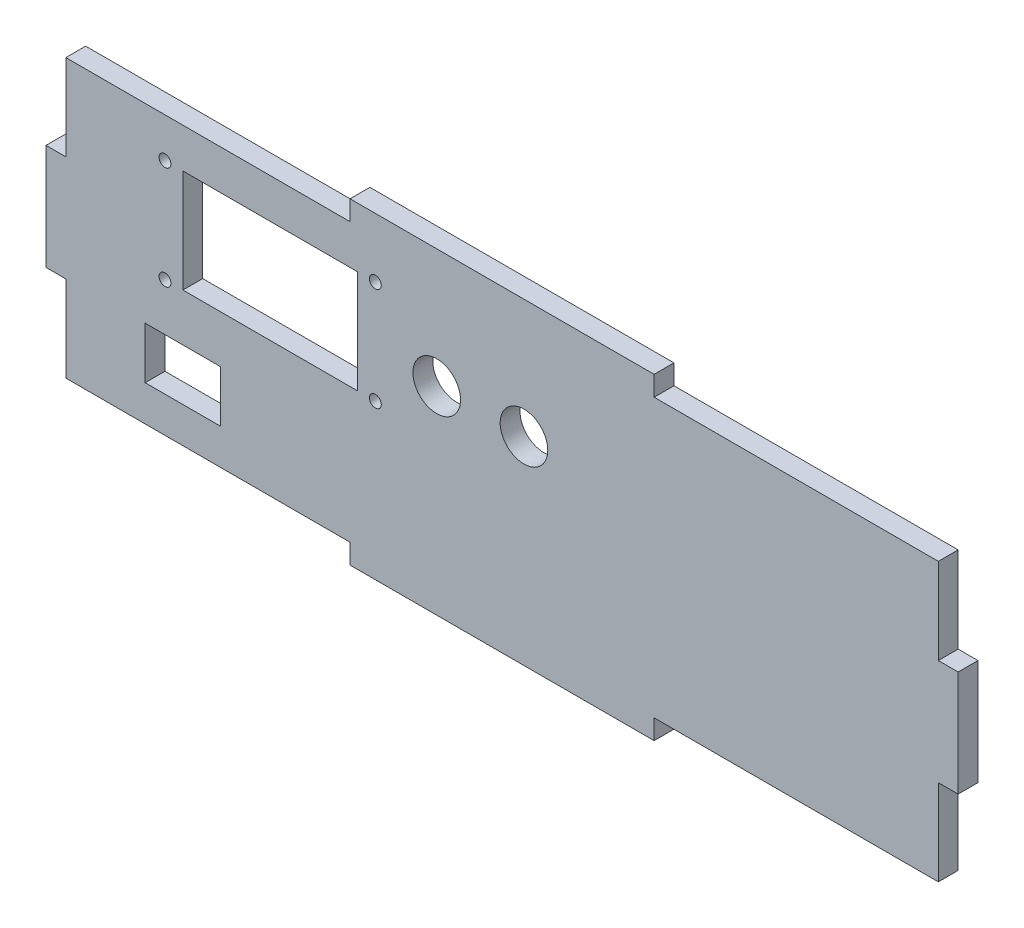
from build123d import *

# Parameters (mm, degrees)
CROQUIS1_R              = 1.5
CROQUIS1_W              = 44
CROQUIS1_H              = 26
CROQUIS1_W_2            = 5
CROQUIS1_H_2            = 26.666666666
CROQUIS1_W_3            = 76.666666666
CROQUIS1_H_3            = 5
SALIENTE_EXTRUIR1_DEPTH = 5
CROQUIS2_R              = 4.15
CORTAR_EXTRUIR1_DEPTH   = 10
CROQUIS3_W              = 19
CROQUIS3_H              = 13
CORTAR_EXTRUIR2_DEPTH   = 10
CROQUIS4_R              = 4.15
CORTAR_EXTRUIR3_DEPTH   = 10
CROQUIS5_R              = 6
CORTAR_EXTRUIR4_DEPTH   = 10
CROQUIS7_W              = 87.958060954
CROQUIS7_H              = 14.714173765
SALIENTE_EXTRUIR2_DEPTH = 5


with BuildPart() as part:
    # Croquis1 → Saliente-Extruir1 (new body)
    with BuildSketch(Plane.XY):
        Polygon((5, 26.666666667), (5, 5), (76.666666667, 5), (153.333333333, 5), (225, 5), (225, 26.666666667), (225, 53.333333333), (225, 75), (153.333333333, 75), (76.666666667, 75), (5, 75), (5, 53.333333333), align=None)
        with Locations((30, 39)):
            Circle(CROQUIS1_R, mode=Mode.SUBTRACT)
        with Locations((83.04, 39)):
            Circle(CROQUIS1_R, mode=Mode.SUBTRACT)
        with Locations((56.52, 52)):
            Rectangle(CROQUIS1_W, CROQUIS1_H, mode=Mode.SUBTRACT)
        with Locations((30, 65)):
            Circle(CROQUIS1_R, mode=Mode.SUBTRACT)
        with Locations((83.04, 65)):
            Circle(CROQUIS1_R, mode=Mode.SUBTRACT)
        with Locations((227.5, 40)):
            Rectangle(CROQUIS1_W_2, CROQUIS1_H_2)
        with Locations((115, 2.5)):
            Rectangle(CROQUIS1_W_3, CROQUIS1_H_3)
        with Locations((2.5, 40)):
            Rectangle(CROQUIS1_W_2, CROQUIS1_H_2)
        with Locations((115, 77.5)):
            Rectangle(CROQUIS1_W_3, CROQUIS1_H_3)
    extrude(amount=SALIENTE_EXTRUIR1_DEPTH)

    # Croquis2 → Cortar-Extruir1 (cut)
    with BuildSketch(Plane.XY.offset(5)):
        with Locations((96.666666667, 20)):
            Circle(CROQUIS2_R)
        with Locations((116.666666667, 20)):
            Circle(CROQUIS2_R)
        with Locations((136.666666667, 20)):
            Circle(CROQUIS2_R)
    extrude(amount=-CORTAR_EXTRUIR1_DEPTH, mode=Mode.SUBTRACT)

    # Croquis3 → Cortar-Extruir2 (cut)
    with BuildSketch(Plane.XY.offset(5)):
        with Locations((34.5, 20.5)):
            Rectangle(CROQUIS3_W, CROQUIS3_H)
    extrude(amount=-CORTAR_EXTRUIR2_DEPTH, mode=Mode.SUBTRACT)

    # Croquis4 → Cortar-Extruir3 (cut)
    with BuildSketch(Plane.XY.offset(5)):
        with Locations((65, 20)):
            Circle(CROQUIS4_R)
        with Locations((80, 20)):
            Circle(CROQUIS4_R)
    extrude(amount=-CORTAR_EXTRUIR3_DEPTH, mode=Mode.SUBTRACT)

    # Croquis5 → Cortar-Extruir4 (cut)
    with BuildSketch(Plane.XY.offset(5)):
        with Locations((98.52, 50)):
            Circle(CROQUIS5_R)
        with Locations((120.52, 50)):
            Circle(CROQUIS5_R)
    extrude(amount=-CORTAR_EXTRUIR4_DEPTH, mode=Mode.SUBTRACT)

    # Croquis7 → Saliente-Extruir2 (add)
    with BuildSketch(Plane.XY.offset(5)):
        with Locations((100.697748768, 19.971943706)):
            Rectangle(CROQUIS7_W, CROQUIS7_H)
    extrude(amount=-SALIENTE_EXTRUIR2_DEPTH)


solid = part.part
